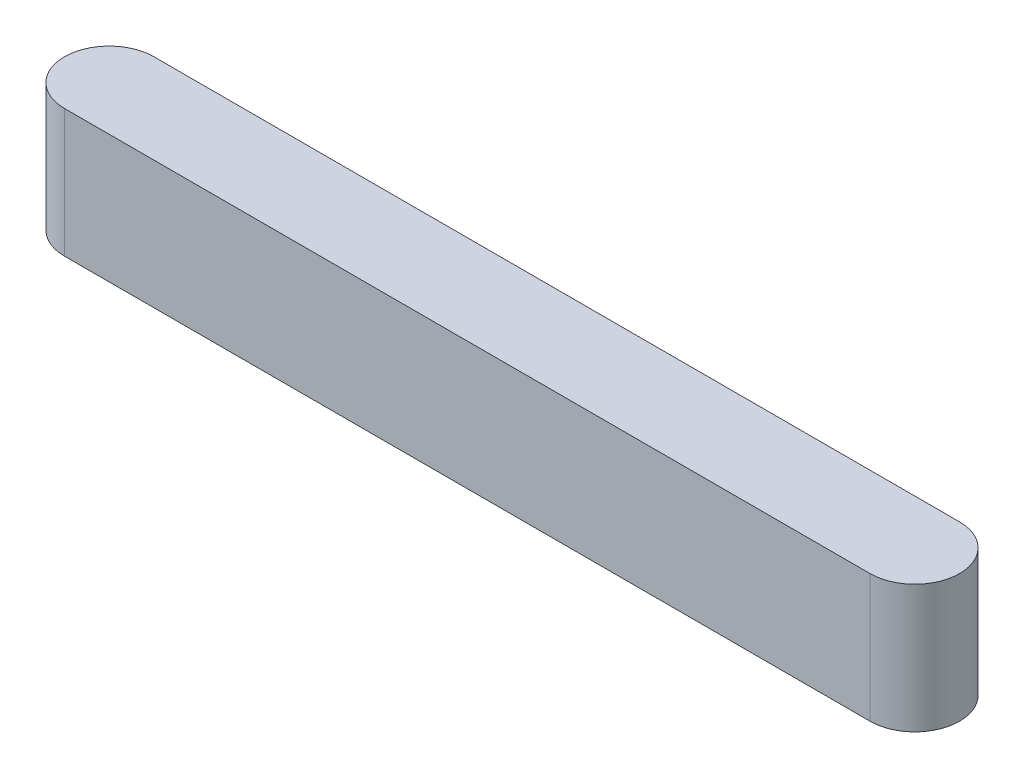
from build123d import *

# Parameters (mm, degrees)
BOSS_EXTRUDE1_DEPTH = 2.8575


with BuildPart() as part:
    # Sketch1 → Boss-Extrude1 (new body)
    with BuildSketch(Plane(origin=(0, 0, 0), x_dir=(1, 0, 0), z_dir=(0, 1, 0))):
        with BuildLine():
            Line((-9, 1), (9, 1))
            ThreePointArc((9, 1), (10, 0), (9, -1))
            Line((9, -1), (-9, -1))
            ThreePointArc((-9, -1), (-10, 0), (-9, 1))
        make_face()
    extrude(amount=BOSS_EXTRUDE1_DEPTH)


solid = part.part
